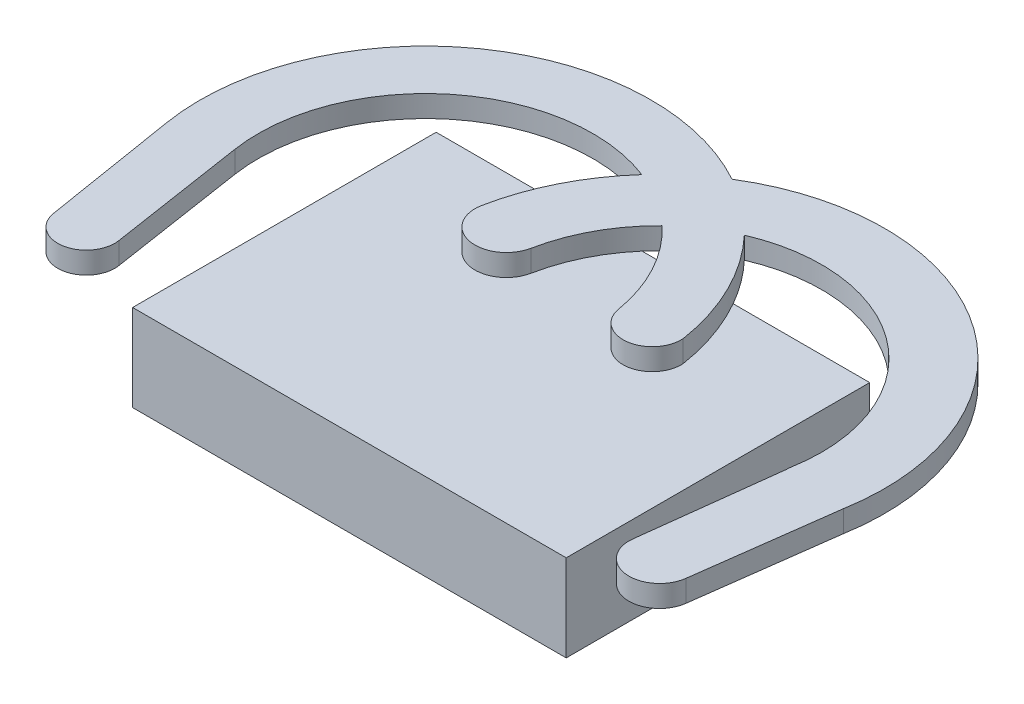
from build123d import *

# Parameters (mm, degrees)
SKETCH2_W           = 63.5
SKETCH2_H           = 12.7
BOSS_EXTRUDE1_DEPTH = 44.45
BOSS_EXTRUDE2_DEPTH = 3.175
SKETCH2_2_W         = 63.5
SKETCH2_2_H         = 12.7
BOSS_EXTRUDE3_DEPTH = 3.175
BOSS_EXTRUDE4_DEPTH = 3.175


with BuildPart() as part:
    # Sketch2 → Boss-Extrude1 (new body)
    with BuildSketch(Plane.XY):
        with Locations((-21.607638889, 1.984375)):
            Rectangle(SKETCH2_W, SKETCH2_H)
    extrude(amount=BOSS_EXTRUDE1_DEPTH)

    # Sketch3 → Boss-Extrude2 (add)
    with BuildSketch(Plane(origin=(0, 8.334375, 0), x_dir=(1, 0, 0), z_dir=(0, 1, 0))):
        with BuildLine():
            Line((27.384230149, -21.096568897), (24.686230398, -41.471557028))
            ThreePointArc((24.686230398, -41.471557028), (19.660883481, -45.321643523), (15.810796986, -40.296296607))
            Line((15.810796986, -40.296296607), (18.234581428, -20.32))
            ThreePointArc((18.234581428, -20.32), (18.251088657, -19.930319533), (18.300492073, -19.543431103))
            ThreePointArc((18.300492073, -19.543431103), (-0.851865875, 7.879150717), (-28.517114145, -10.920978184))
            ThreePointArc((-28.517114145, -10.920978184), (-33.930101581, -14.549040236), (-37.558163632, -9.136052801))
            ThreePointArc((-37.558163632, -9.136052801), (0.817302189, 16.942285518), (27.384230149, -21.096568897))
        make_face()
    extrude(amount=BOSS_EXTRUDE2_DEPTH)

    # Sketch2_2 → Boss-Extrude3 (add)
    with BuildSketch(Plane.XY):
        with Locations((-21.607638889, 1.984375)):
            Rectangle(SKETCH2_2_W, SKETCH2_2_H)
    extrude(amount=BOSS_EXTRUDE3_DEPTH)

    # Sketch6 → Boss-Extrude4 (add)
    with BuildSketch(Plane(origin=(0, 8.334375, 0), x_dir=(1, 0, 0), z_dir=(0, 1, 0))):
        with BuildLine():
            Line((-71.134197224, -21.655068851), (-67.914165266, -41.469070044))
            ThreePointArc((-67.914165266, -41.469070044), (-63.143827484, -44.92106421), (-59.671631072, -40.165410907))
            Line((-59.671631072, -40.165410907), (-62.760560613, -20.083656097))
            ThreePointArc((-62.760560613, -20.083656097), (-42.464339717, 7.82922996), (-14.386949358, -12.238802862))
            ThreePointArc((-14.386949358, -12.238802862), (-9.684746174, -15.772440511), (-5.918655002, -11.254269741))
            ThreePointArc((-5.918655002, -11.254269741), (-43.742205026, 16.249534133), (-71.134197224, -21.655068851))
        make_face()
    extrude(amount=BOSS_EXTRUDE4_DEPTH)


solid = part.part
